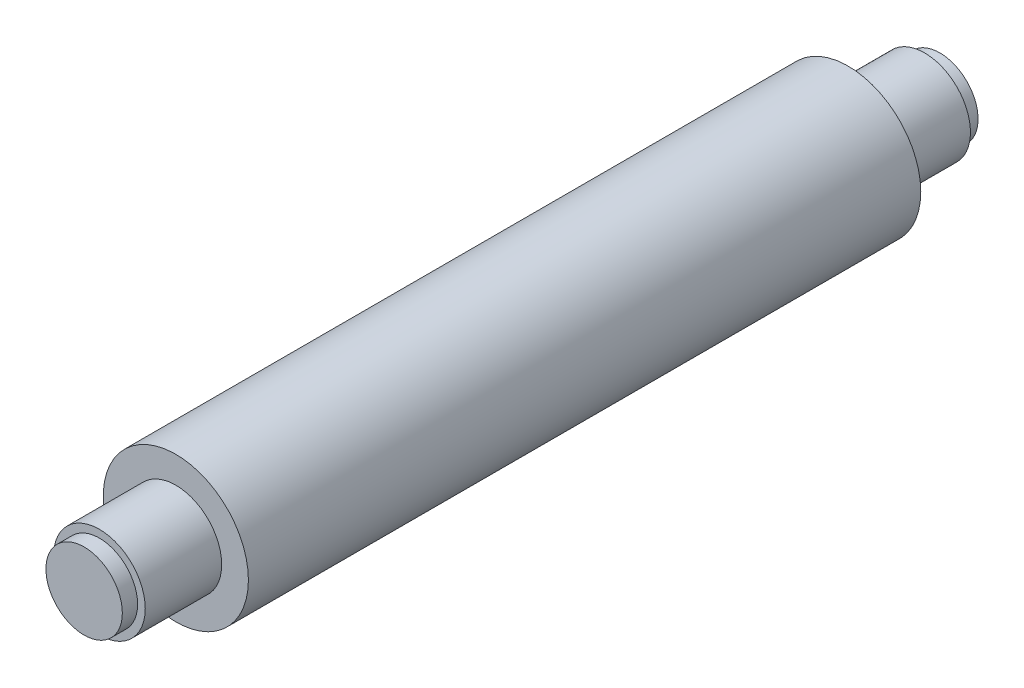
from build123d import *

# Parameters (mm, degrees)
SKETCH1_R           = 47.5
BOSS_EXTRUDE1_DEPTH = 440
SKETCH2_R           = 30
BOSS_EXTRUDE2_DEPTH = 50
SKETCH3_R           = 30
BOSS_EXTRUDE3_DEPTH = 50
SKETCH4_R           = 25
BOSS_EXTRUDE4_DEPTH = 10
SKETCH5_R           = 25
BOSS_EXTRUDE5_DEPTH = 10


with BuildPart() as part:
    # Sketch1 → Boss-Extrude1 (new body)
    with BuildSketch(Plane.XY):
        Circle(SKETCH1_R)
    extrude(amount=BOSS_EXTRUDE1_DEPTH)

    # Sketch2 → Boss-Extrude2 (add)
    with BuildSketch(Plane(origin=(0, 0, 0), x_dir=(-1, 0, 0), z_dir=(0, 0, -1))):
        Circle(SKETCH2_R)
    extrude(amount=BOSS_EXTRUDE2_DEPTH)

    # Sketch3 → Boss-Extrude3 (add)
    with BuildSketch(Plane.XY.offset(440)):
        Circle(SKETCH3_R)
    extrude(amount=BOSS_EXTRUDE3_DEPTH)

    # Sketch4 → Boss-Extrude4 (add)
    with BuildSketch(Plane.XY.offset(490)):
        Circle(SKETCH4_R)
    extrude(amount=BOSS_EXTRUDE4_DEPTH)

    # Sketch5 → Boss-Extrude5 (add)
    with BuildSketch(Plane(origin=(0, 0, -50), x_dir=(-1, 0, 0), z_dir=(0, 0, -1))):
        Circle(SKETCH5_R)
    extrude(amount=BOSS_EXTRUDE5_DEPTH)


solid = part.part
